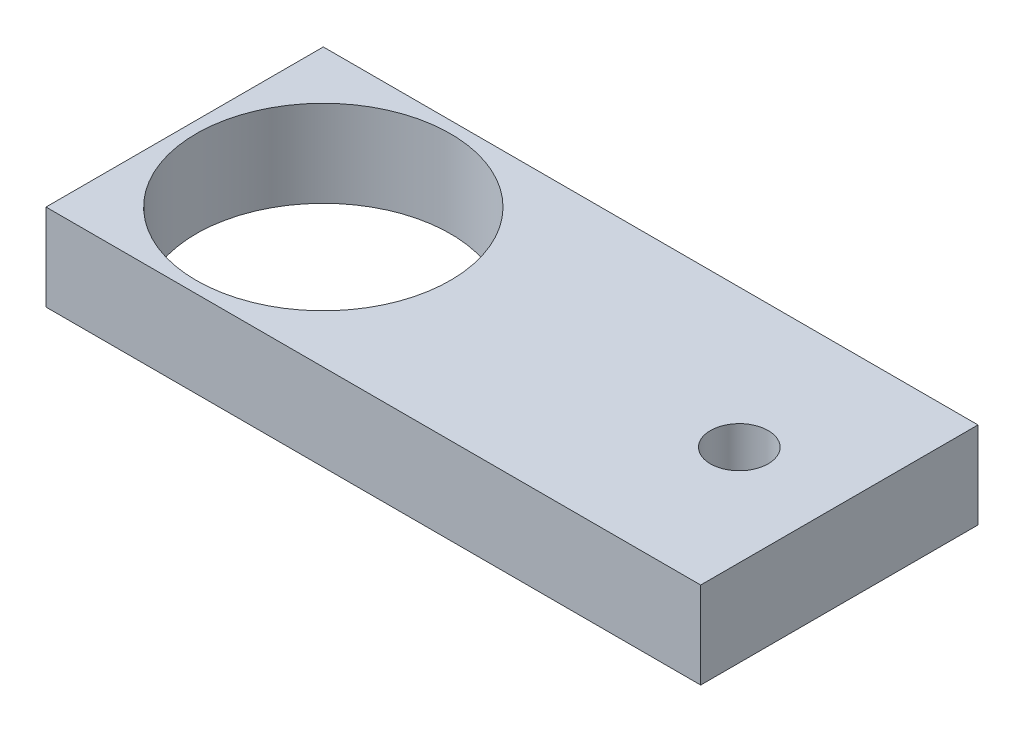
from build123d import *

# Parameters (mm, degrees)
SKETCH1_W           = 113.319310707
SKETCH1_H           = 48
SKETCH1_R           = 22
SKETCH1_R_2         = 5
BOSS_EXTRUDE1_DEPTH = 15


with BuildPart() as part:
    # Sketch1 → Boss-Extrude1 (new body)
    with BuildSketch(Plane(origin=(0, 0, 0), x_dir=(1, 0, 0), z_dir=(0, 1, 0))):
        with Locations((56.659655354, 24)):
            Rectangle(SKETCH1_W, SKETCH1_H)
        with Locations((24, 24)):
            Circle(SKETCH1_R, mode=Mode.SUBTRACT)
        with Locations((96, 24)):
            Circle(SKETCH1_R_2, mode=Mode.SUBTRACT)
    extrude(amount=BOSS_EXTRUDE1_DEPTH)


solid = part.part
